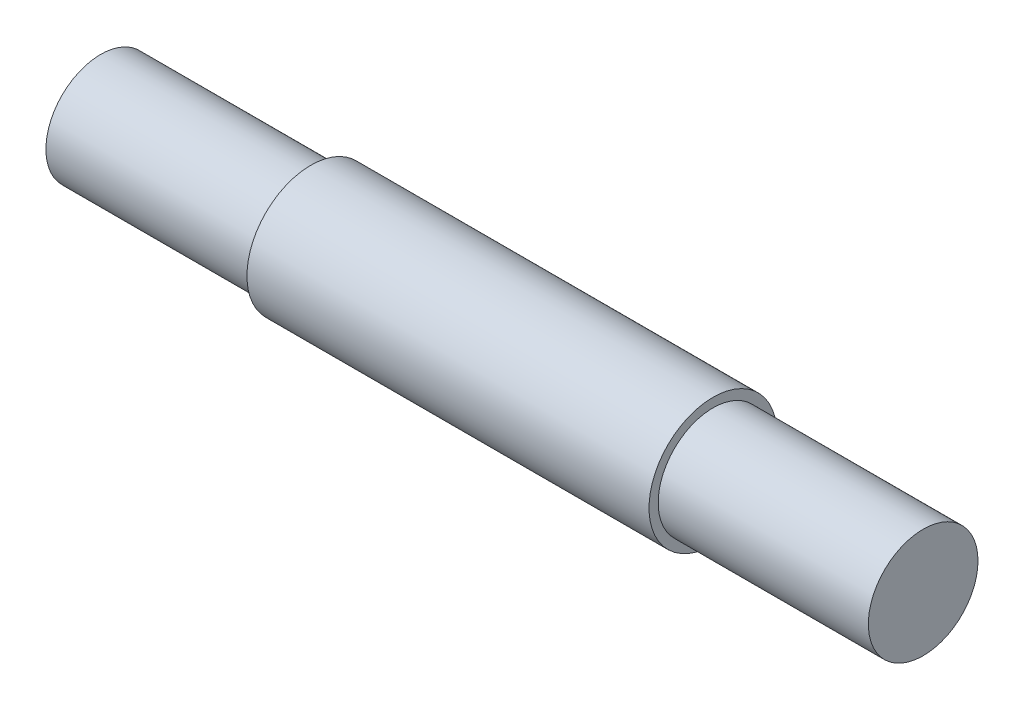
from build123d import *

# Parameters (mm, degrees)
SKETCH1_R               = 4.445
BOSS_EXTRUDE1_DEPTH     = 28.575
SKETCH2_R               = 6.35
SKETCH2_R_2             = 3.81
CUT_EXTRUDE_THIN1_DEPTH = 14.605


with BuildPart() as part:
    # Sketch1 → Boss-Extrude1 (new body, symmetric)
    with BuildSketch(Plane(origin=(0, 0, 0), x_dir=(0, 0, -1), z_dir=(1, 0, 0))):
        Circle(SKETCH1_R)
    extrude(amount=BOSS_EXTRUDE1_DEPTH, both=True)

    # Sketch2 → Cut-Extrude-Thin1 (cut)
    with BuildSketch(Plane(origin=(28.575, 0, 0), x_dir=(0, 0, -1), z_dir=(1, 0, 0))):
        Circle(SKETCH2_R)
        Circle(SKETCH2_R_2, mode=Mode.SUBTRACT)
    cut_extrude_thin1 = extrude(amount=-CUT_EXTRUDE_THIN1_DEPTH, mode=Mode.SUBTRACT)

    # Mirror1: Cut-Extrude-Thin1 across plane
    add(cut_extrude_thin1.mirror(Plane(origin=(0, 0, 0), x_dir=(0, 0, 1), z_dir=(1, 0, 0))), mode=Mode.SUBTRACT)


solid = part.part
